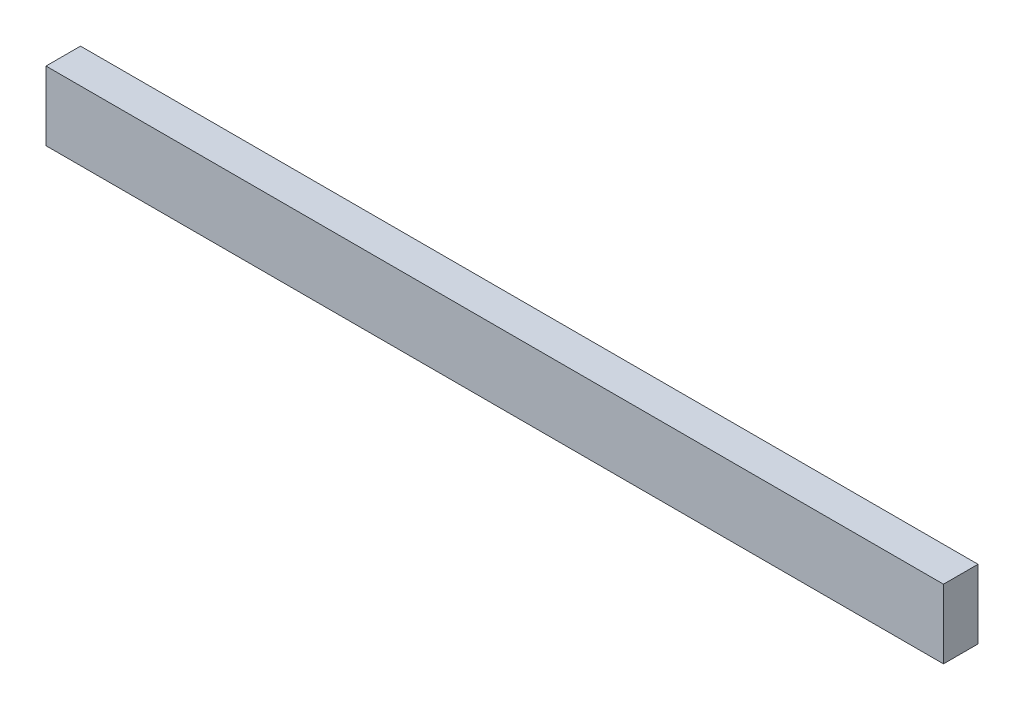
from build123d import *

# Parameters (mm, degrees)
SKETCH1_W           = 260
SKETCH1_H           = 20
BOSS_EXTRUDE1_DEPTH = 10


with BuildPart() as part:
    # Sketch1 → Boss-Extrude1 (new body)
    with BuildSketch(Plane.XY):
        Rectangle(SKETCH1_W, SKETCH1_H)
    extrude(amount=-BOSS_EXTRUDE1_DEPTH)


solid = part.part
